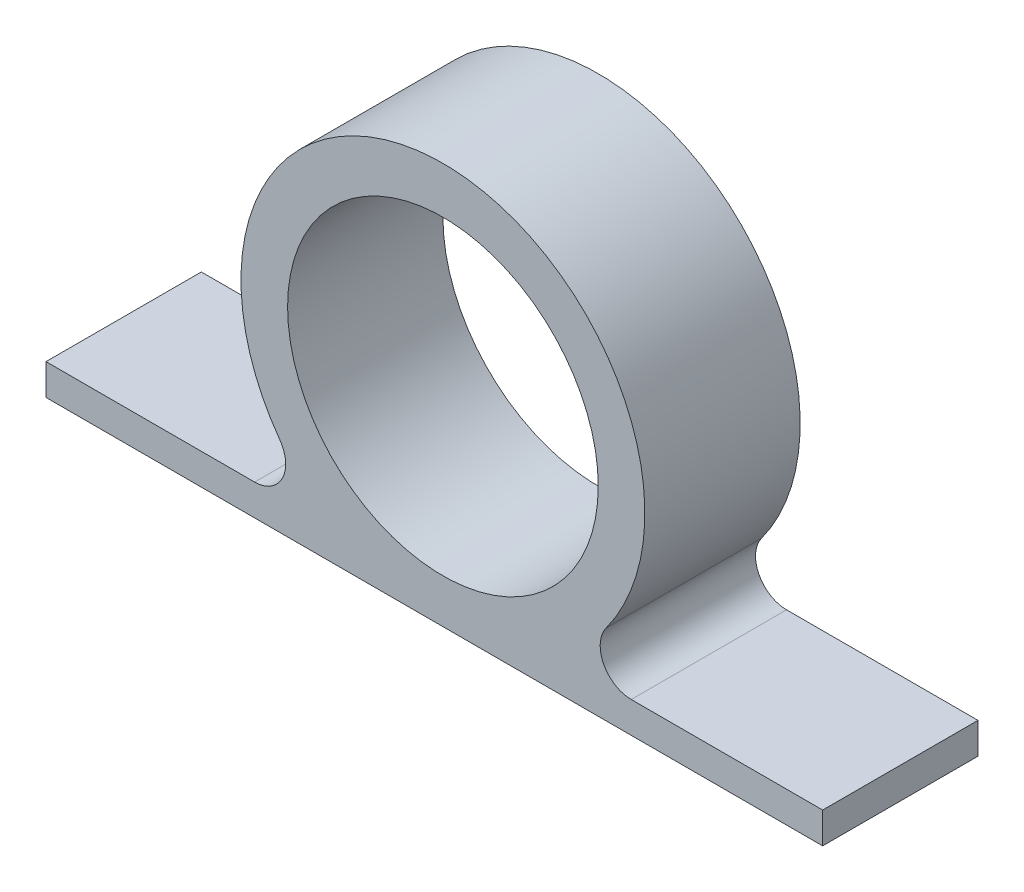
from build123d import *

# Parameters (mm, degrees)
ESQUISSE1_R        = 10
BOSS_EXTRU_3_DEPTH = 10


with BuildPart() as part:
    # Esquisse1 → Boss.-Extru.3 (new body)
    with BuildSketch(Plane.XY):
        with BuildLine():
            Line((0, -12.833333333), (-25.552770798, -12.833333333))
            Line((-25.552770798, -12.833333333), (-25.552770798, -10.833333333))
            Line((-25.552770798, -10.833333333), (-12.123210063, -10.833333333))
            ThreePointArc((-12.123210063, -10.833333333), (-10.340577802, -9.740098034), (-10.506782054, -7.655555556))
            ThreePointArc((-10.506782054, -7.655555556), (0, 13), (10.506782054, -7.655555556))
            ThreePointArc((10.506782054, -7.655555556), (10.340577802, -9.740098034), (12.123210063, -10.833333333))
            Line((12.123210063, -10.833333333), (24.447229202, -10.833333333))
            Line((24.447229202, -10.833333333), (24.447229202, -12.833333333))
            Line((24.447229202, -12.833333333), (0, -12.833333333))
        make_face()
        Circle(ESQUISSE1_R, mode=Mode.SUBTRACT)
    extrude(amount=BOSS_EXTRU_3_DEPTH)


solid = part.part
